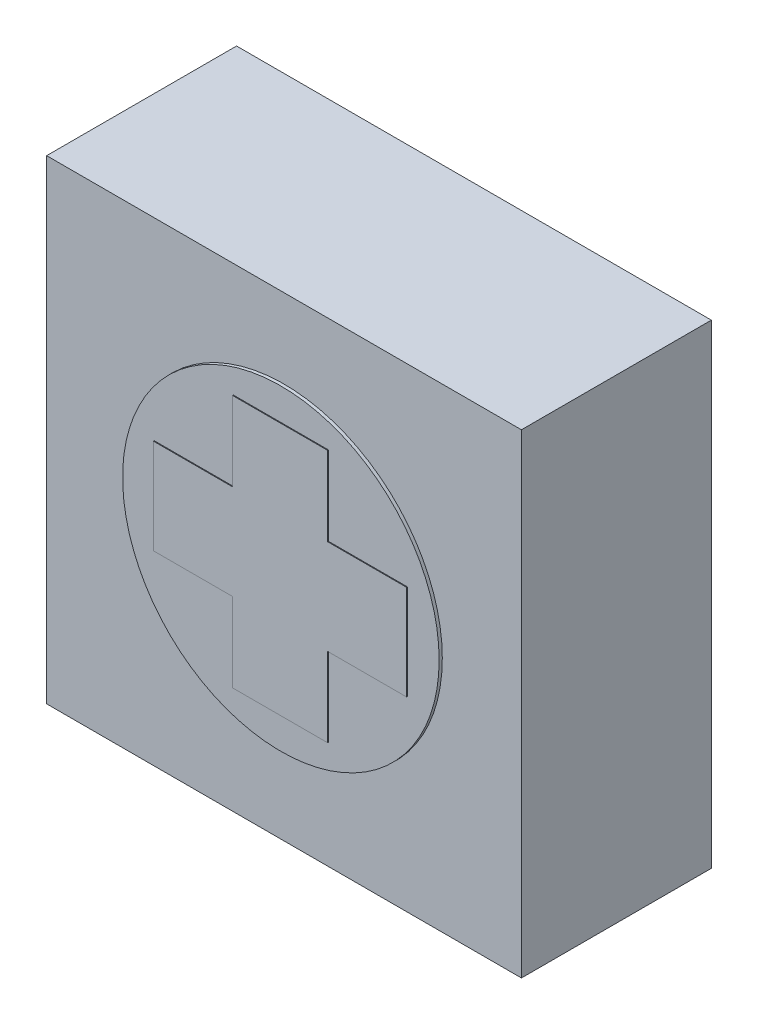
from build123d import *

# Parameters (mm, degrees)
SKETCH1_W           = 150
SKETCH1_H           = 150
BOSS_EXTRUDE1_DEPTH = 30
SKETCH2_R           = 50
BOSS_EXTRUDE2_DEPTH = 1
SKETCH3_W           = 25
SKETCH3_H           = 30
SKETCH3_W_2         = 30
SKETCH3_H_2         = 25
BOSS_EXTRUDE3_DEPTH = 1.25
SCALE1_SCALE        = 0.5


with BuildPart() as part:
    # Sketch1 → Boss-Extrude1 (new body, symmetric)
    with BuildSketch(Plane.XY):
        Rectangle(SKETCH1_W, SKETCH1_H)
    extrude(amount=BOSS_EXTRUDE1_DEPTH, both=True)

    # Sketch2 → Boss-Extrude2 (add)
    with BuildSketch(Plane.XY.offset(30)):
        Circle(SKETCH2_R)
    extrude(amount=BOSS_EXTRUDE2_DEPTH)

    # Sketch3 → Boss-Extrude3 (add)
    with BuildSketch(Plane.XY.offset(30)):
        with Locations((-27.5, 0)):
            Rectangle(SKETCH3_W, SKETCH3_H)
        Rectangle(SKETCH3_W_2, SKETCH3_H)
        with Locations((0, 27.5)):
            Rectangle(SKETCH3_W_2, SKETCH3_H_2)
        with Locations((27.5, 0)):
            Rectangle(SKETCH3_W, SKETCH3_H)
        with Locations((0, -27.5)):
            Rectangle(SKETCH3_W_2, SKETCH3_H_2)
    extrude(amount=BOSS_EXTRUDE3_DEPTH)


with BuildPart() as part_1:
    # Scale1: scaled about (0, 0, 0.198621989)
    add(part.part.scale(SCALE1_SCALE).moved(Location((0, 0, 0.099310994))))


solid = part_1.part
